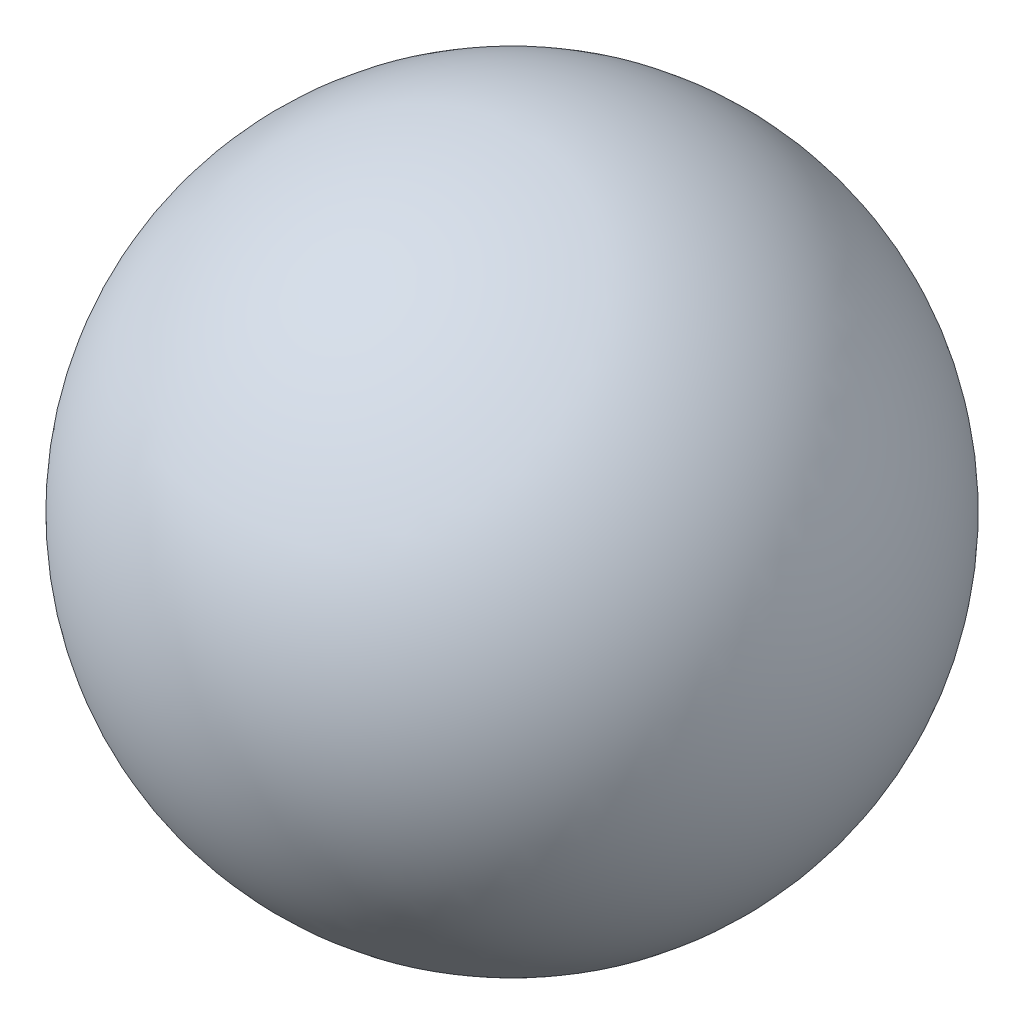
from build123d import *


with BuildPart() as part:
    # Sketch1 → Revolve1 (revolve)
    with BuildSketch(Plane.XY):
        with BuildLine():
            Line((0, 11.25), (0, -11.25))
            ThreePointArc((0, -11.25), (11.25, 0), (0, 11.25))
        make_face()
    revolve(axis=Axis((0, 11.25, 0), (0, -1, 0)))


solid = part.part
